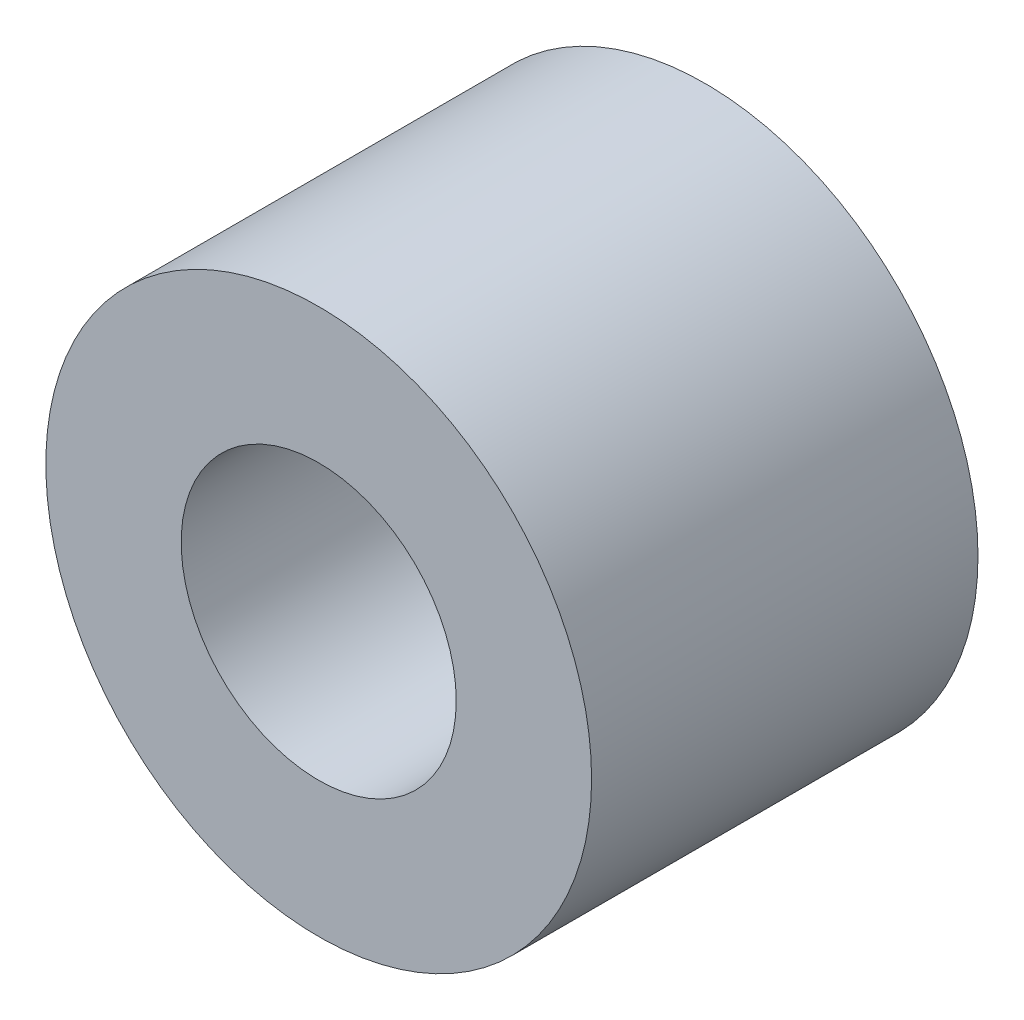
from build123d import *

# Parameters (mm, degrees)
SKETCH1_R           = 6.35
SKETCH1_R_2         = 3.2004
BOSS_EXTRUDE1_DEPTH = 8.9916


with BuildPart() as part:
    # Sketch1 → Boss-Extrude1 (new body)
    with BuildSketch(Plane.XY):
        Circle(SKETCH1_R)
        Circle(SKETCH1_R_2, mode=Mode.SUBTRACT)
    extrude(amount=BOSS_EXTRUDE1_DEPTH)


solid = part.part
